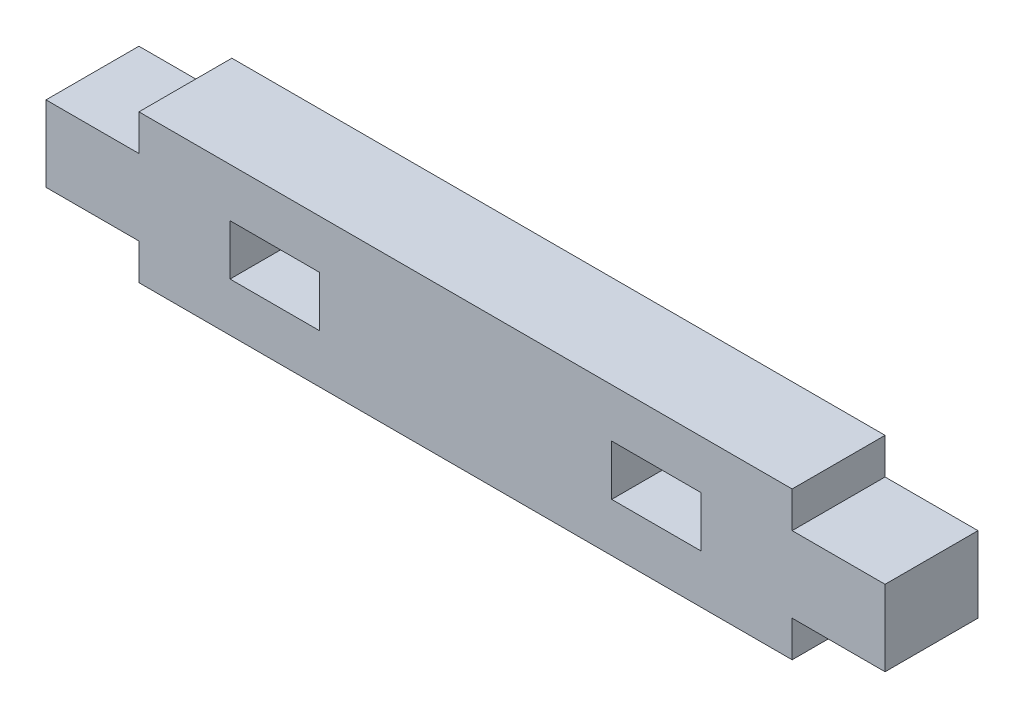
from build123d import *

# Parameters (mm, degrees)
BOSS_EXTRUDE1_DEPTH = 5.15
SKETCH2_W           = 4.95
SKETCH2_H           = 2.8
CUT_EXTRUDE1_DEPTH  = 6.15


with BuildPart() as part:
    # Sketch1 → Boss-Extrude1 (new body)
    with BuildSketch(Plane.XY):
        Polygon((-18.1, 1.9), (-18.1, -0.1), (0, -0.1), (18.1, -0.1), (18.1, 1.9), (23.25, 1.9), (23.25, 6.1), (18.1, 6.1), (18.1, 8.1), (-18.1, 8.1), (-18.1, 6.1), (-23.25, 6.1), (-23.25, 1.9), align=None)
    extrude(amount=BOSS_EXTRUDE1_DEPTH)

    # Sketch2 → Cut-Extrude1 (cut, through all)
    with BuildSketch(Plane.XY.offset(5.15)):
        with Locations((-10.575, 4)):
            Rectangle(SKETCH2_W, SKETCH2_H)
        with Locations((10.575, 4)):
            Rectangle(SKETCH2_W, SKETCH2_H)
    extrude(amount=-CUT_EXTRUDE1_DEPTH, mode=Mode.SUBTRACT)


solid = part.part
